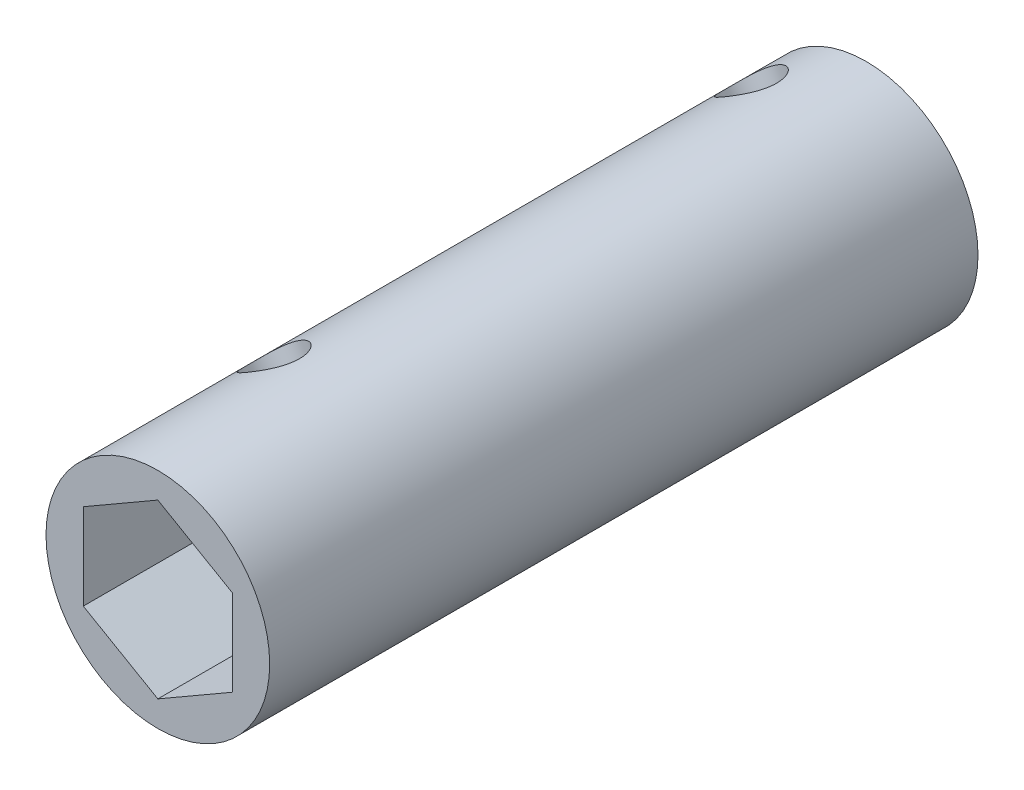
from build123d import *

# Parameters (mm, degrees)
SKETCH1_R               = 9.525
BOSS_EXTRUDE1_DEPTH     = 60.325
SKETCH3_R               = 2.38125
CUT_EXTRUDE1_DEPTH      = 24.171391971
CUT_EXTRUDE1_DEPTH_BACK = 3.851391971


with BuildPart() as part:
    # Sketch1 → Boss-Extrude1 (new body)
    with BuildSketch(Plane.XY):
        Circle(SKETCH1_R)
        Polygon((6.35, 3.666174209), (0, 7.332348419), (-6.35, 3.666174209), (-6.35, -3.666174209), (0, -7.332348419), (6.35, -3.666174209), align=None, mode=Mode.SUBTRACT)
    extrude(amount=BOSS_EXTRUDE1_DEPTH)

    # Sketch3 → Cut-Extrude1 (cut, two sides)
    with BuildSketch(Plane(origin=(5.08, -8.798818102, 0), x_dir=(0.866025404, 0.5, 0), z_dir=(-0.5, 0.866025404, 0))) as cut_extrude1_sk:
        with Locations((0, -5.08)):
            Circle(SKETCH3_R)
        with Locations((0, -45.72)):
            Circle(SKETCH3_R)
    extrude(amount=CUT_EXTRUDE1_DEPTH, mode=Mode.SUBTRACT)
    extrude(cut_extrude1_sk.sketch, amount=-CUT_EXTRUDE1_DEPTH_BACK, mode=Mode.SUBTRACT)


solid = part.part
